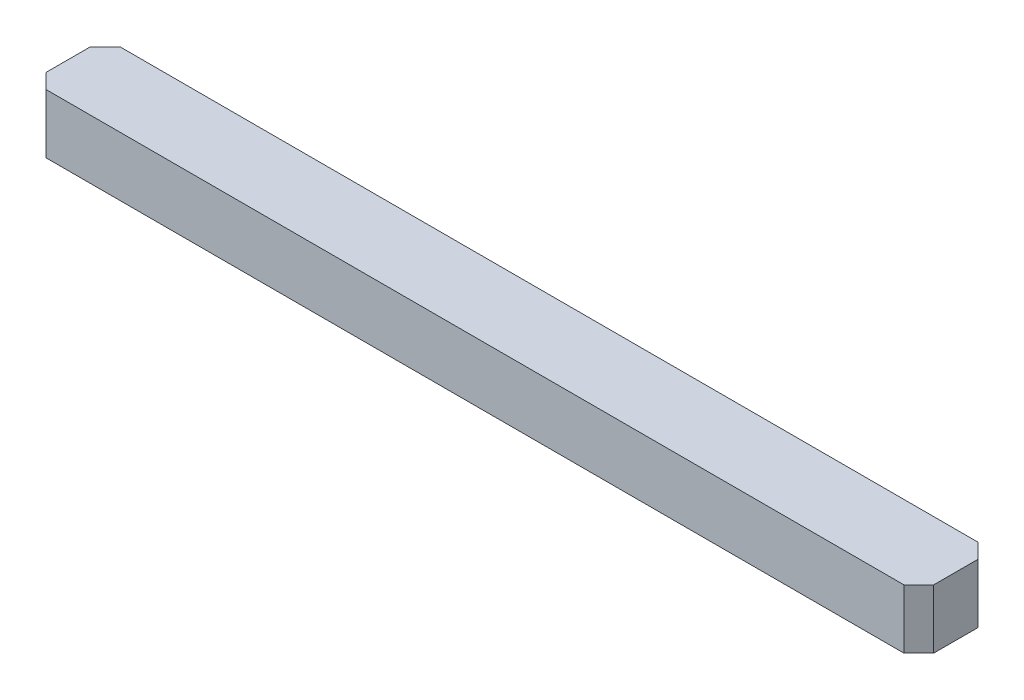
from build123d import *

# Parameters (mm, degrees)
SKETCH1_W           = 60
SKETCH1_H           = 5
BOSS_EXTRUDE1_DEPTH = 4
CHAMFER1_SIZE       = 1


with BuildPart() as part:
    # Sketch1 → Boss-Extrude1 (new body)
    with BuildSketch(Plane(origin=(0, 0, 0), x_dir=(1, 0, 0), z_dir=(0, 1, 0))):
        with Locations((30, 2.5)):
            Rectangle(SKETCH1_W, SKETCH1_H)
    extrude(amount=BOSS_EXTRUDE1_DEPTH)

    # Chamfer1
    chamfer1_edges = [part.edges().sort_by_distance(p)[0] for p in [
        (0, 2, -5),
        (60, 2, -5),
        (60, 2, 0),
        (0, 2, 0),
    ]]
    chamfer(chamfer1_edges, length=CHAMFER1_SIZE)


solid = part.part
